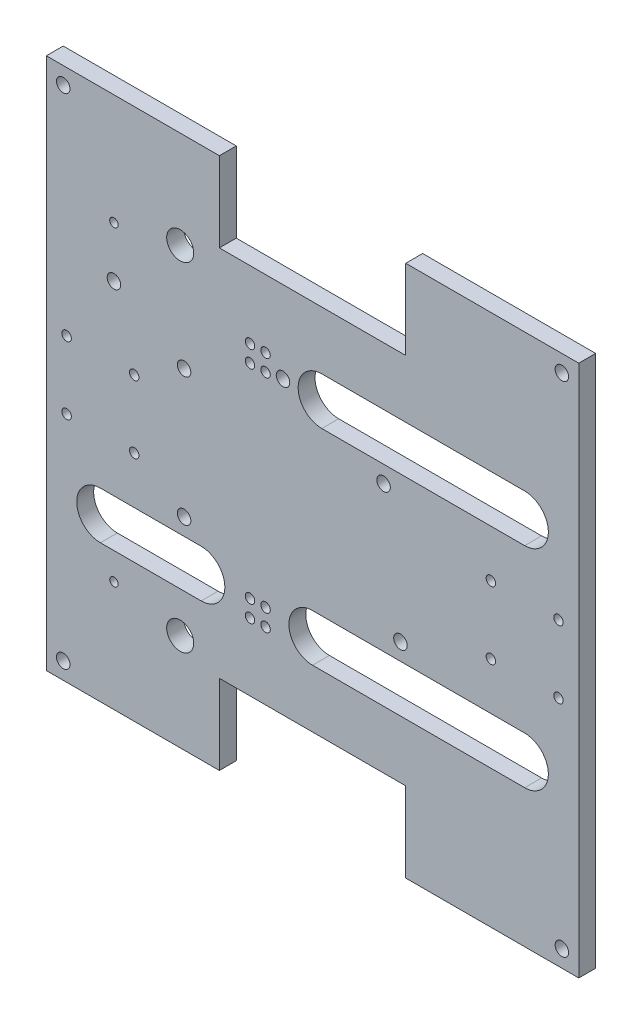
from build123d import *

# Parameters (mm, degrees)
SKETCH1_R           = 1.5875
SKETCH1_R_2         = 1.778
SKETCH1_R_3         = 2.54
SKETCH1_R_4         = 5.08
BOSS_EXTRUDE1_DEPTH = 6.35


with BuildPart() as part:
    # Sketch1 → Boss-Extrude1 (new body)
    with BuildSketch(Plane.XY):
        Polygon((249.789850187, 150.240558714), (314.789850187, 150.240558714), (314.789850187, -49.759441286), (249.789850187, -49.759441286), (249.789850187, -19.759441286), (179.789850187, -19.759441286), (179.789850187, -49.759441286), (114.789850187, -49.759441286), (114.789850187, 150.240558714), (179.789850187, 150.240558714), (179.789850187, 120.240558714), (249.789850187, 120.240558714), align=None)
        with Locations((140.189850187, -8.179441286)):
            Circle(SKETCH1_R, mode=Mode.SUBTRACT)
        with Locations((122.409850187, 62.940558714)):
            Circle(SKETCH1_R_2, mode=Mode.SUBTRACT)
        with Locations((122.409850187, 37.540558714)):
            Circle(SKETCH1_R_2, mode=Mode.SUBTRACT)
        with Locations((147.809850187, 37.540558714)):
            Circle(SKETCH1_R_2, mode=Mode.SUBTRACT)
        with Locations((140.189850187, 108.660558714)):
            Circle(SKETCH1_R, mode=Mode.SUBTRACT)
        with Locations((147.809850187, 62.940558714)):
            Circle(SKETCH1_R_2, mode=Mode.SUBTRACT)
        with Locations((281.769850187, 62.940558714)):
            Circle(SKETCH1_R_2, mode=Mode.SUBTRACT)
        with Locations((307.169850187, 62.940558714)):
            Circle(SKETCH1_R_2, mode=Mode.SUBTRACT)
        with Locations((281.769850187, 37.540558714)):
            Circle(SKETCH1_R_2, mode=Mode.SUBTRACT)
        with Locations((307.169850187, 37.540558714)):
            Circle(SKETCH1_R_2, mode=Mode.SUBTRACT)
        with Locations((121.139850187, 143.890558714)):
            Circle(SKETCH1_R_3, mode=Mode.SUBTRACT)
        with Locations((140.189850187, 89.597220113)):
            Circle(SKETCH1_R_3, mode=Mode.SUBTRACT)
        with Locations((203.689850187, 89.597220113)):
            Circle(SKETCH1_R_3, mode=Mode.SUBTRACT)
        with Locations((191.294850187, 11.990558714)):
            Circle(SKETCH1_R_2, mode=Mode.SUBTRACT)
        with Locations((197.136850187, 11.990558714)):
            Circle(SKETCH1_R_2, mode=Mode.SUBTRACT)
        with Locations((191.294850187, 5.640558714)):
            Circle(SKETCH1_R_2, mode=Mode.SUBTRACT)
        with Locations((197.136850187, 5.640558714)):
            Circle(SKETCH1_R_2, mode=Mode.SUBTRACT)
        with Locations((191.294850187, 94.840558714)):
            Circle(SKETCH1_R_2, mode=Mode.SUBTRACT)
        with Locations((191.294850187, 88.490558714)):
            Circle(SKETCH1_R_2, mode=Mode.SUBTRACT)
        with Locations((197.136850187, 88.490558714)):
            Circle(SKETCH1_R_2, mode=Mode.SUBTRACT)
        with Locations((197.136850187, 94.840558714)):
            Circle(SKETCH1_R_2, mode=Mode.SUBTRACT)
        with Locations((166.529850187, 74.370558714)):
            Circle(SKETCH1_R_3, mode=Mode.SUBTRACT)
        with Locations((241.459850187, 74.370558714)):
            Circle(SKETCH1_R_3, mode=Mode.SUBTRACT)
        with Locations((166.529850187, 26.110558714)):
            Circle(SKETCH1_R_3, mode=Mode.SUBTRACT)
        with Locations((247.809850187, 26.110558714)):
            Circle(SKETCH1_R_3, mode=Mode.SUBTRACT)
        with Locations((121.139850187, -43.409441286)):
            Circle(SKETCH1_R_3, mode=Mode.SUBTRACT)
        with Locations((308.439850187, -43.409441286)):
            Circle(SKETCH1_R_3, mode=Mode.SUBTRACT)
        with Locations((308.439850187, 143.890558714)):
            Circle(SKETCH1_R_3, mode=Mode.SUBTRACT)
        with Locations((165.076665974, 113.740558714)):
            Circle(SKETCH1_R_4, mode=Mode.SUBTRACT)
        with Locations((165.076665974, -13.259441286)):
            Circle(SKETCH1_R_4, mode=Mode.SUBTRACT)
        with BuildLine():
            Line((135.109850187, 19.760558714), (172.953168155, 19.760558714))
            ThreePointArc((172.953168155, 19.760558714), (181.843168155, 10.870558714), (172.953168155, 1.980558714))
            Line((172.953168155, 1.980558714), (135.109850187, 1.980558714))
            ThreePointArc((135.109850187, 1.980558714), (126.219850187, 10.870558714), (135.109850187, 19.760558714))
        make_face(mode=Mode.SUBTRACT)
        with BuildLine():
            Line((218.269850187, 98.500558714), (294.469850187, 98.500558714))
            ThreePointArc((294.469850187, 98.500558714), (303.359850187, 89.610558714), (294.469850187, 80.720558714))
            Line((294.469850187, 80.720558714), (218.269850187, 80.720558714))
            ThreePointArc((218.269850187, 80.720558714), (209.379850187, 89.610558714), (218.269850187, 98.500558714))
        make_face(mode=Mode.SUBTRACT)
        with BuildLine():
            Line((214.789850187, 1.980558714), (294.469850187, 1.980558714))
            ThreePointArc((294.469850187, 1.980558714), (303.359850187, 10.870558714), (294.469850187, 19.760558714))
            Line((294.469850187, 19.760558714), (214.789850187, 19.760558714))
            ThreePointArc((214.789850187, 19.760558714), (205.899850187, 10.870558714), (214.789850187, 1.980558714))
        make_face(mode=Mode.SUBTRACT)
    extrude(amount=BOSS_EXTRUDE1_DEPTH)


solid = part.part
